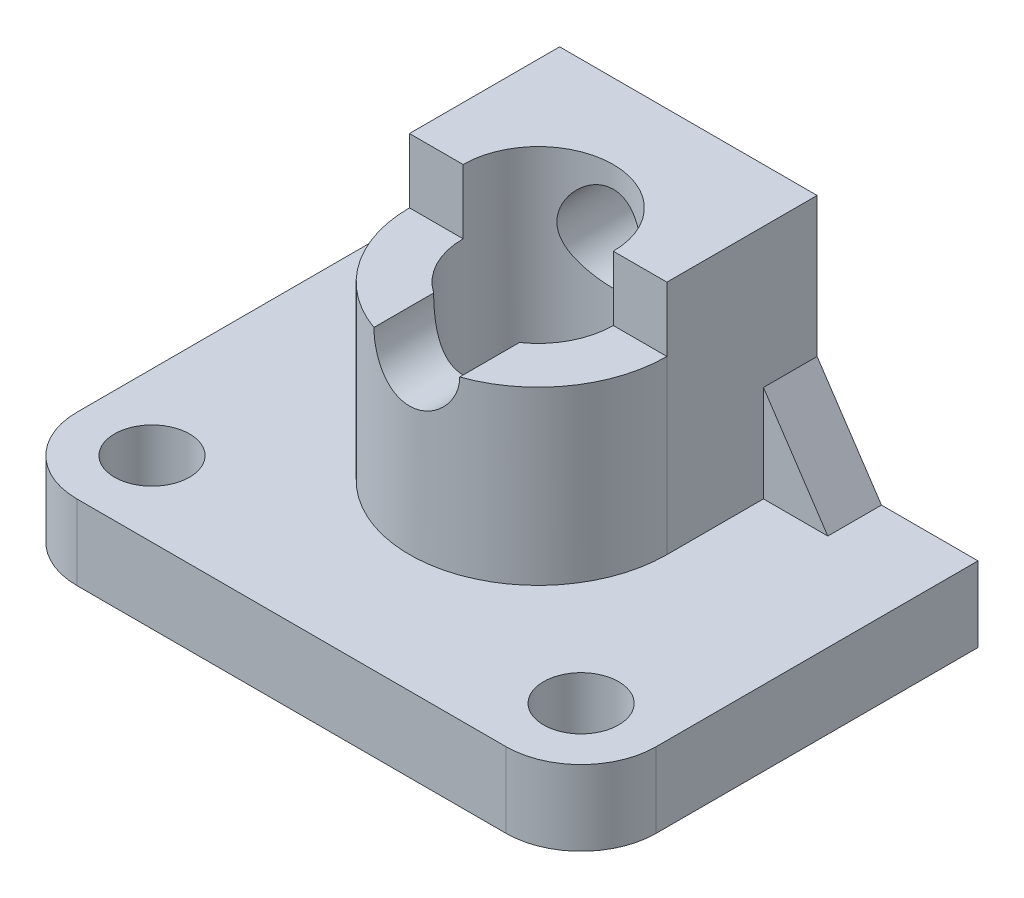
from build123d import *

# Parameters (mm, degrees)
EXTRUDE_1_DEPTH          = 7
SKETCH_2_R               = 3.5
CUT_EXTRUDE_2_DEPTH      = 7
FILLET_1_R               = 7
EXTRUDE_2_DEPTH          = 29
SKETCH_4_R               = 7
CUT_EXTRUDE_3_DEPTH      = 30
CUT_EXTRUDE_4_DEPTH      = 6
SKETCH_6_R               = 4
CUT_EXTRUDE_5_DEPTH      = 17
CUT_EXTRUDE_5_DEPTH_BACK = 15
EXTRUDE_3_DEPTH          = 5


with BuildPart() as part:
    # 草图1 → 凸台-拉伸1 (new body)
    with BuildSketch(Plane(origin=(0, 0, 0), x_dir=(1, 0, 0), z_dir=(0, 1, 0))):
        Polygon((0, 0), (27, 0), (27, -37), (-27, -37), (-27, 0), align=None)
    extrude(amount=EXTRUDE_1_DEPTH)

    # 草图2 → 切除-拉伸2 (cut)
    with BuildSketch(Plane(origin=(0, 0, 0), x_dir=(1, 0, 0), z_dir=(0, 1, 0))):
        with Locations((-20, -30)):
            Circle(SKETCH_2_R)
        with Locations((20, -30)):
            Circle(SKETCH_2_R)
    extrude(amount=CUT_EXTRUDE_2_DEPTH, mode=Mode.SUBTRACT)

    # 圆角1
    fillet_1_edges = [part.edges().sort_by_distance(p)[0] for p in [
        (27, 3.5, 37),
        (-27, 3.5, 37),
    ]]
    fillet(fillet_1_edges, radius=FILLET_1_R)

    # 草图3 → 凸台-拉伸2 (add)
    with BuildSketch(Plane(origin=(0, 0, 0), x_dir=(1, 0, 0), z_dir=(0, 1, 0))):
        with BuildLine():
            Line((0, 0), (-12, 0))
            Line((-12, 0), (-12, -14))
            ThreePointArc((-12, -14), (0, -26), (12, -14))
            Line((12, -14), (12, 0))
            Line((12, 0), (0, 0))
        make_face()
    extrude(amount=EXTRUDE_2_DEPTH)

    # 草图4 → 切除-拉伸3 (cut, through all)
    with BuildSketch(Plane(origin=(0, 29, 0), x_dir=(1, 0, 0), z_dir=(0, 1, 0))):
        with Locations((0, -14)):
            Circle(SKETCH_4_R)
    extrude(amount=-CUT_EXTRUDE_3_DEPTH, mode=Mode.SUBTRACT)

    # 草图5 → 切除-拉伸4 (cut)
    with BuildSketch(Plane(origin=(0, 29, 0), x_dir=(1, 0, 0), z_dir=(0, 1, 0))):
        with BuildLine():
            Line((-7, -14), (-12, -14))
            ThreePointArc((-12, -14), (0, -26), (12, -14))
            Line((12, -14), (7, -14))
            ThreePointArc((7, -14), (0, -21), (-7, -14))
        make_face()
    extrude(amount=-CUT_EXTRUDE_4_DEPTH, mode=Mode.SUBTRACT)

    # 草图6 → 切除-拉伸5 (cut, two sides)
    with BuildSketch(Plane.XY.offset(14)) as cut_extrude_5_sk:
        with Locations((0, 23)):
            Circle(SKETCH_6_R)
    extrude(amount=CUT_EXTRUDE_5_DEPTH, mode=Mode.SUBTRACT)
    extrude(cut_extrude_5_sk.sketch, amount=-CUT_EXTRUDE_5_DEPTH_BACK, mode=Mode.SUBTRACT)

    # 草图8 → 凸台-拉伸3 (add)
    with BuildSketch(Plane.XY):
        Polygon((-12, 16), (-18, 7), (-12, 7), align=None)
        Polygon((12, 7), (12, 16), (18, 7), align=None)
    extrude(amount=EXTRUDE_3_DEPTH)


solid = part.part
